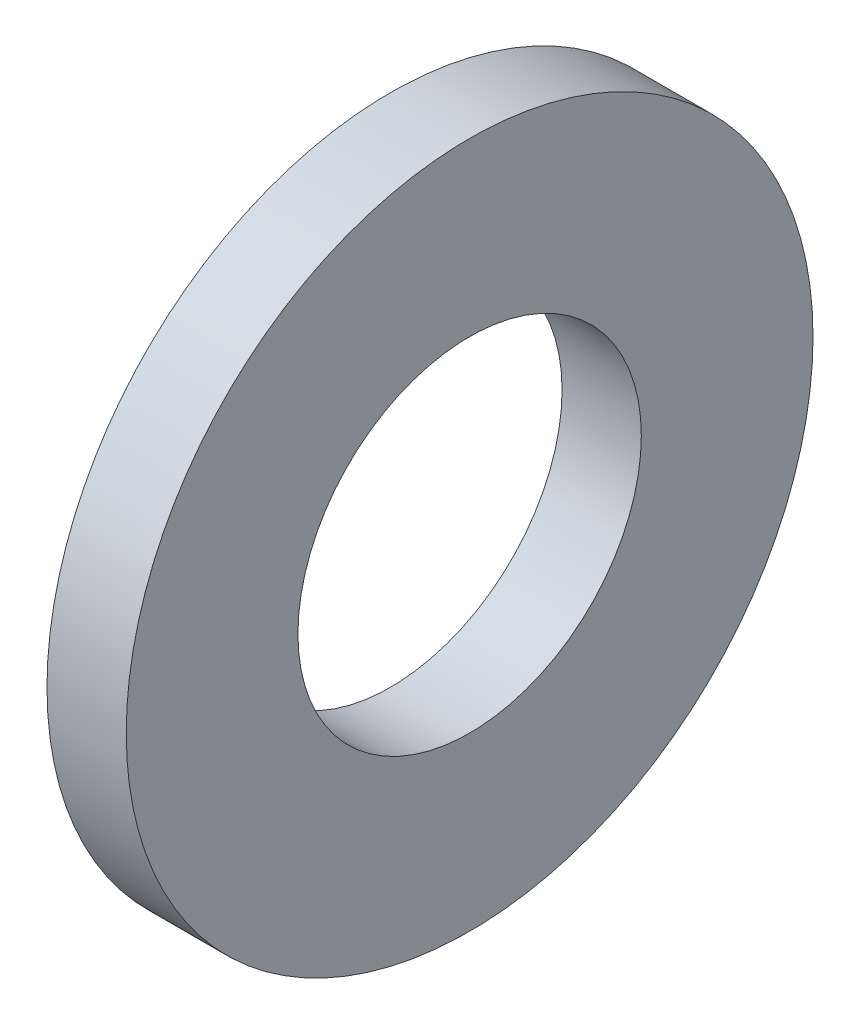
from build123d import *

# Parameters (mm, degrees)
SKETCH1_R           = 3.9624
SKETCH1_R_2         = 1.9812
BOSS_EXTRUDE1_DEPTH = 0.9144


with BuildPart() as part:
    # Sketch1 → Boss-Extrude1 (new body)
    with BuildSketch(Plane(origin=(0, 0, 0), x_dir=(0, 0, -1), z_dir=(1, 0, 0))):
        Circle(SKETCH1_R)
        Circle(SKETCH1_R_2, mode=Mode.SUBTRACT)
    extrude(amount=BOSS_EXTRUDE1_DEPTH)


solid = part.part
